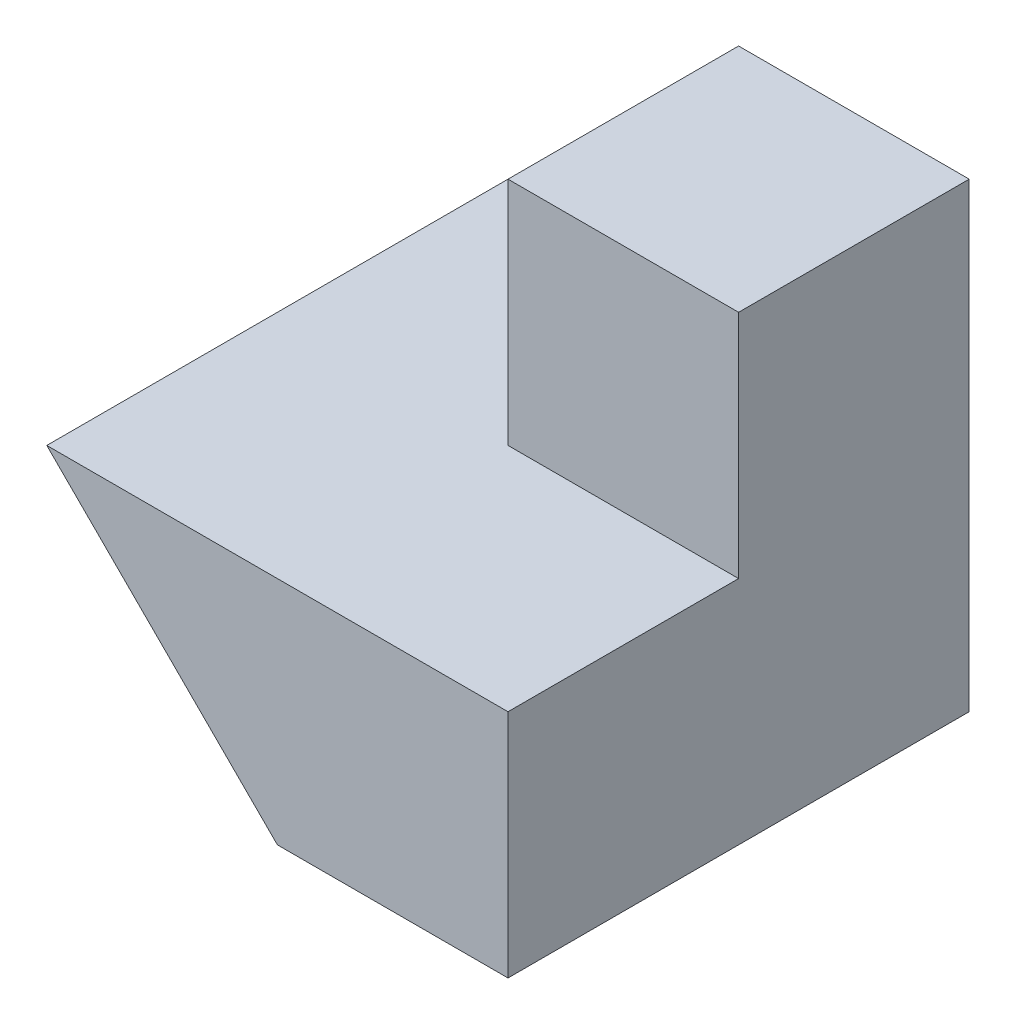
from build123d import *

# Parameters (mm, degrees)
SKETCH1_W           = 40
SKETCH1_H           = 40
BOSS_EXTRUDE1_DEPTH = 40
SKETCH2_W           = 20
SKETCH2_H           = 20
CUT_EXTRUDE1_DEPTH  = 40
SKETCH3_W           = 20
SKETCH3_H           = 20
CUT_EXTRUDE2_DEPTH  = 40
CUT_EXTRUDE3_DEPTH  = 20


with BuildPart() as part:
    # Sketch1 → Boss-Extrude1 (new body)
    with BuildSketch(Plane.XY):
        with Locations((20, 20)):
            Rectangle(SKETCH1_W, SKETCH1_H)
    extrude(amount=BOSS_EXTRUDE1_DEPTH)

    # Sketch2 → Cut-Extrude1 (cut)
    with BuildSketch(Plane.XY.offset(40)):
        with Locations((10, 30)):
            Rectangle(SKETCH2_W, SKETCH2_H)
    extrude(amount=-CUT_EXTRUDE1_DEPTH, mode=Mode.SUBTRACT)

    # Sketch3 → Cut-Extrude2 (cut)
    with BuildSketch(Plane.ZY.offset(-20)):
        with Locations((30, 30)):
            Rectangle(SKETCH3_W, SKETCH3_H)
    extrude(amount=-CUT_EXTRUDE2_DEPTH, mode=Mode.SUBTRACT)

    # Sketch4 → Cut-Extrude3 (cut)
    with BuildSketch(Plane.XY.offset(40)):
        Polygon((0, 20), (20, 0), (0, 0), align=None)
    extrude(amount=-CUT_EXTRUDE3_DEPTH, mode=Mode.SUBTRACT)


solid = part.part
